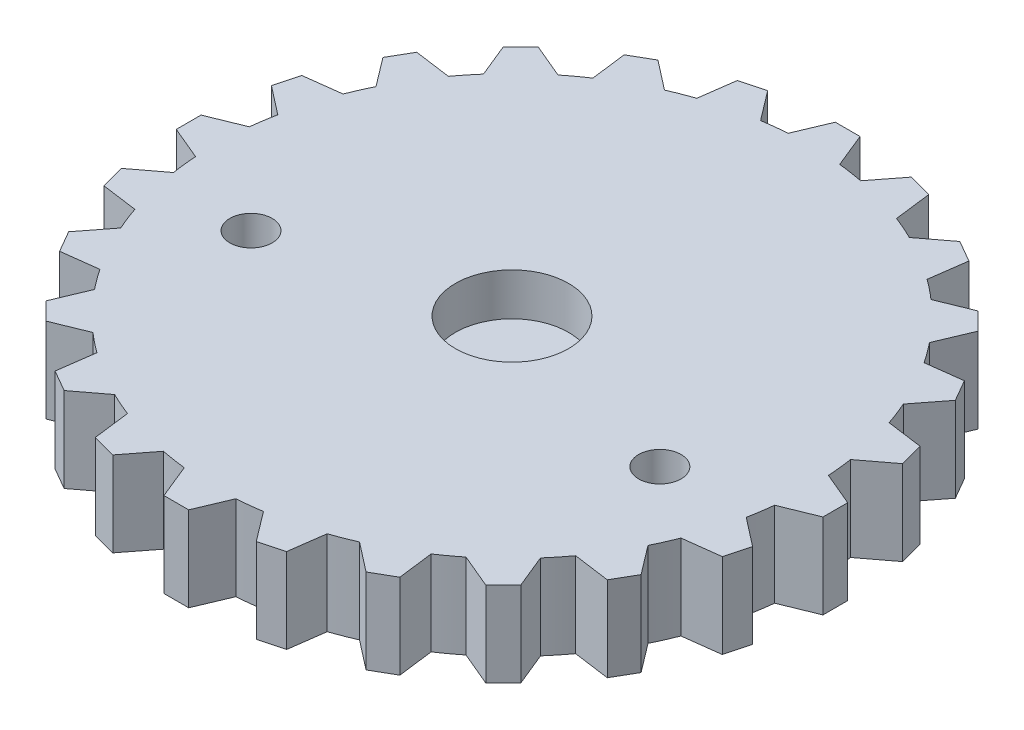
from build123d import *

# Parameters (mm, degrees)
BOSS_EXTRUDE5_DEPTH = 6
BOSS_EXTRUDE6_DEPTH = 3
SKETCH4_R           = 4
CUT_EXTRUDE1_DEPTH  = 10
SKETCH5_R           = 1.5
CUT_EXTRUDE2_DEPTH  = 7


with BuildPart() as part:
    # Sketch3 → Boss-Extrude5 (new body)
    with BuildSketch(Plane(origin=(0, 0, 0), x_dir=(1, 0, 0), z_dir=(0, 1, 0))):
        with BuildLine():
            Line((23.301465589, -1.311541929), (23.301465589, 0.438458071))
            Line((23.301465589, 0.438458071), (20.951465589, 1.426916143))
            ThreePointArc((20.951465589, 1.426916143), (20.873013262, 2.30593091), (20.757698449, 3.180873321))
            Line((20.757698449, 3.180873321), (22.846939432, 4.764010852))
            Line((22.846939432, 4.764010852), (22.394006103, 6.454381048))
            Line((22.394006103, 6.454381048), (19.868248637, 6.800933471))
            ThreePointArc((19.868248637, 6.800933471), (19.564963746, 7.629691581), (19.227126431, 8.444975382))
            Line((19.227126431, 8.444975382), (20.83543211, 10.514904166))
            Line((20.83543211, 10.514904166), (19.96043211, 12.030448623))
            Line((19.96043211, 12.030448623), (17.431043375, 11.711478423))
            ThreePointArc((17.431043375, 11.711478423), (16.923594283, 12.433501379), (16.386257521, 13.133566327))
            Line((16.386257521, 13.133566327), (17.404024521, 15.549224138))
            Line((17.404024521, 15.549224138), (16.166587654, 16.786661005))
            Line((16.166587654, 16.786661005), (13.805941313, 15.823905474))
            ThreePointArc((13.805941313, 15.823905474), (13.128909838, 16.389988605), (12.42869224, 16.927126431))
            Line((12.42869224, 16.927126431), (12.786561423, 19.523890181))
            Line((12.786561423, 19.523890181), (11.271016966, 20.398890181))
            Line((11.271016966, 20.398890181), (9.239987166, 18.857959518))
            ThreePointArc((9.239987166, 18.857959518), (8.439511883, 19.229525194), (7.624132122, 19.567130842))
            Line((7.624132122, 19.567130842), (7.297715294, 22.168035373))
            Line((7.297715294, 22.168035373), (5.607345098, 22.620968702))
            Line((5.607345098, 22.620968702), (4.044343163, 20.606874784))
            ThreePointArc((4.044343163, 20.606874784), (3.174975141, 20.758601419), (2.3, 20.873667622))
            Line((2.3, 20.873667622), (1.311541929, 23.301465589))
            Line((1.311541929, 23.301465589), (-0.438458071, 23.301465589))
            Line((-0.438458071, 23.301465589), (-1.426916143, 20.951465589))
            ThreePointArc((-1.426916143, 20.951465589), (-2.30593091, 20.873013262), (-3.180873321, 20.757698449))
            Line((-3.180873321, 20.757698449), (-4.764010852, 22.846939432))
            Line((-4.764010852, 22.846939432), (-6.454381048, 22.394006103))
            Line((-6.454381048, 22.394006103), (-6.800933471, 19.868248637))
            ThreePointArc((-6.800933471, 19.868248637), (-7.629691581, 19.564963746), (-8.444975382, 19.227126431))
            Line((-8.444975382, 19.227126431), (-10.514904166, 20.83543211))
            Line((-10.514904166, 20.83543211), (-12.030448623, 19.96043211))
            Line((-12.030448623, 19.96043211), (-11.711478423, 17.431043375))
            ThreePointArc((-11.711478423, 17.431043375), (-12.433501379, 16.923594283), (-13.133566327, 16.386257521))
            Line((-13.133566327, 16.386257521), (-15.549224138, 17.404024521))
            Line((-15.549224138, 17.404024521), (-16.786661005, 16.166587654))
            Line((-16.786661005, 16.166587654), (-15.823905474, 13.805941313))
            ThreePointArc((-15.823905474, 13.805941313), (-16.389988605, 13.128909838), (-16.927126431, 12.42869224))
            Line((-16.927126431, 12.42869224), (-19.523890181, 12.786561423))
            Line((-19.523890181, 12.786561423), (-20.398890181, 11.271016966))
            Line((-20.398890181, 11.271016966), (-18.857959518, 9.239987166))
            ThreePointArc((-18.857959518, 9.239987166), (-19.229525194, 8.439511883), (-19.567130842, 7.624132122))
            Line((-19.567130842, 7.624132122), (-22.168035373, 7.297715294))
            Line((-22.168035373, 7.297715294), (-22.620968702, 5.607345098))
            Line((-22.620968702, 5.607345098), (-20.606874784, 4.044343163))
            ThreePointArc((-20.606874784, 4.044343163), (-20.758601419, 3.174975141), (-20.873667622, 2.3))
            Line((-20.873667622, 2.3), (-23.301465589, 1.311541929))
            Line((-23.301465589, 1.311541929), (-23.301465589, -0.438458071))
            Line((-23.301465589, -0.438458071), (-20.951465589, -1.426916143))
            ThreePointArc((-20.951465589, -1.426916143), (-20.873013262, -2.30593091), (-20.757698449, -3.180873321))
            Line((-20.757698449, -3.180873321), (-22.846939432, -4.764010852))
            Line((-22.846939432, -4.764010852), (-22.394006103, -6.454381048))
            Line((-22.394006103, -6.454381048), (-19.868248637, -6.800933471))
            ThreePointArc((-19.868248637, -6.800933471), (-19.564963746, -7.629691581), (-19.227126431, -8.444975382))
            Line((-19.227126431, -8.444975382), (-20.83543211, -10.514904166))
            Line((-20.83543211, -10.514904166), (-19.96043211, -12.030448623))
            Line((-19.96043211, -12.030448623), (-17.431043375, -11.711478423))
            ThreePointArc((-17.431043375, -11.711478423), (-16.923594283, -12.433501379), (-16.386257521, -13.133566327))
            Line((-16.386257521, -13.133566327), (-17.404024521, -15.549224138))
            Line((-17.404024521, -15.549224138), (-16.166587654, -16.786661005))
            Line((-16.166587654, -16.786661005), (-13.805941313, -15.823905474))
            ThreePointArc((-13.805941313, -15.823905474), (-13.128909838, -16.389988605), (-12.42869224, -16.927126431))
            Line((-12.42869224, -16.927126431), (-12.786561423, -19.523890181))
            Line((-12.786561423, -19.523890181), (-11.271016966, -20.398890181))
            Line((-11.271016966, -20.398890181), (-9.239987166, -18.857959518))
            ThreePointArc((-9.239987166, -18.857959518), (-8.439511883, -19.229525194), (-7.624132122, -19.567130842))
            Line((-7.624132122, -19.567130842), (-7.297715294, -22.168035373))
            Line((-7.297715294, -22.168035373), (-5.607345098, -22.620968702))
            Line((-5.607345098, -22.620968702), (-4.044343163, -20.606874784))
            ThreePointArc((-4.044343163, -20.606874784), (-3.174975141, -20.758601419), (-2.3, -20.873667622))
            Line((-2.3, -20.873667622), (-1.311541929, -23.301465589))
            Line((-1.311541929, -23.301465589), (0.438458071, -23.301465589))
            Line((0.438458071, -23.301465589), (1.426916143, -20.951465589))
            ThreePointArc((1.426916143, -20.951465589), (2.30593091, -20.873013262), (3.180873321, -20.757698449))
            Line((3.180873321, -20.757698449), (4.764010852, -22.846939432))
            Line((4.764010852, -22.846939432), (6.454381048, -22.394006103))
            Line((6.454381048, -22.394006103), (6.800933471, -19.868248637))
            ThreePointArc((6.800933471, -19.868248637), (7.629691581, -19.564963746), (8.444975382, -19.227126431))
            Line((8.444975382, -19.227126431), (10.514904166, -20.83543211))
            Line((10.514904166, -20.83543211), (12.030448623, -19.96043211))
            Line((12.030448623, -19.96043211), (11.711478423, -17.431043375))
            ThreePointArc((11.711478423, -17.431043375), (12.433501379, -16.923594283), (13.133566327, -16.386257521))
            Line((13.133566327, -16.386257521), (15.549224138, -17.404024521))
            Line((15.549224138, -17.404024521), (16.786661005, -16.166587654))
            Line((16.786661005, -16.166587654), (15.823905474, -13.805941313))
            ThreePointArc((15.823905474, -13.805941313), (16.389988605, -13.128909838), (16.927126431, -12.42869224))
            Line((16.927126431, -12.42869224), (19.523890181, -12.786561423))
            Line((19.523890181, -12.786561423), (20.398890181, -11.271016966))
            Line((20.398890181, -11.271016966), (18.857959518, -9.239987166))
            ThreePointArc((18.857959518, -9.239987166), (19.229525194, -8.439511883), (19.567130842, -7.624132122))
            Line((19.567130842, -7.624132122), (22.168035373, -7.297715294))
            Line((22.168035373, -7.297715294), (22.620968702, -5.607345098))
            Line((22.620968702, -5.607345098), (20.606874784, -4.044343163))
            ThreePointArc((20.606874784, -4.044343163), (20.758601419, -3.174975141), (20.873667622, -2.3))
            Line((20.873667622, -2.3), (23.301465589, -1.311541929))
        make_face()
    extrude(amount=BOSS_EXTRUDE5_DEPTH)

    # Sketch4 → Cut-Extrude1 (cut)
    with BuildSketch(Plane(origin=(0, 6, 0), x_dir=(1, 0, 0), z_dir=(0, 1, 0))):
        Circle(SKETCH4_R)
    extrude(amount=-CUT_EXTRUDE1_DEPTH, mode=Mode.SUBTRACT)

    # Sketch5 → Cut-Extrude2 (cut, through all)
    with BuildSketch(Plane(origin=(0, 6, 0), x_dir=(1, 0, 0), z_dir=(0, 1, 0))):
        with Locations((-14.456832295, -4)):
            Circle(SKETCH5_R)
        with Locations((14.456832295, -4)):
            Circle(SKETCH5_R)
    extrude(amount=-CUT_EXTRUDE2_DEPTH, mode=Mode.SUBTRACT)


with BuildPart() as body_2:
    # Sketch1 → Boss-Extrude6 (new body)
    with BuildSketch(Plane(origin=(0, 0, 0), x_dir=(1, 0, 0), z_dir=(0, 1, 0))):
        with BuildLine():
            Line((-0.5, 14.746169466), (0.5, 14.746169466))
            Line((0.5, 14.746169466), (2, 12.544128437))
            ThreePointArc((2, 12.544128437), (2.588190451, 12.405427729), (3.166928678, 12.23145084))
            Line((3.166928678, 12.23145084), (5.566987298, 13.388474311))
            Line((5.566987298, 13.388474311), (6.433012702, 12.888474311))
            Line((6.433012702, 12.888474311), (6.631030293, 10.23145084))
            ThreePointArc((6.631030293, 10.23145084), (7.071067812, 9.817237278), (7.485281374, 9.377199759))
            Line((7.485281374, 9.377199759), (10.142304845, 9.179182168))
            Line((10.142304845, 9.179182168), (10.642304845, 8.313156764))
            Line((10.642304845, 8.313156764), (9.485281374, 5.913098144))
            ThreePointArc((9.485281374, 5.913098144), (9.659258263, 5.334359917), (9.797958971, 4.746169466))
            Line((9.797958971, 4.746169466), (12, 3.246169466))
            Line((12, 3.246169466), (12, 2.246169466))
            Line((12, 2.246169466), (9.797958971, 0.746169466))
            ThreePointArc((9.797958971, 0.746169466), (9.659258263, 0.157979015), (9.485281374, -0.420759212))
            Line((9.485281374, -0.420759212), (10.642304845, -2.820817832))
            Line((10.642304845, -2.820817832), (10.142304845, -3.686843236))
            Line((10.142304845, -3.686843236), (7.485281374, -3.884860827))
            ThreePointArc((7.485281374, -3.884860827), (7.071067812, -4.324898346), (6.631030293, -4.739111908))
            Line((6.631030293, -4.739111908), (6.433012702, -7.39613538))
            Line((6.433012702, -7.39613538), (5.566987298, -7.89613538))
            Line((5.566987298, -7.89613538), (3.166928678, -6.739111908))
            ThreePointArc((3.166928678, -6.739111908), (2.588190451, -6.913088797), (2, -7.051789505))
            Line((2, -7.051789505), (0.5, -9.253830534))
            Line((0.5, -9.253830534), (-0.5, -9.253830534))
            Line((-0.5, -9.253830534), (-2, -7.051789505))
            ThreePointArc((-2, -7.051789505), (-2.588190451, -6.913088797), (-3.166928678, -6.739111908))
            Line((-3.166928678, -6.739111908), (-5.566987298, -7.89613538))
            Line((-5.566987298, -7.89613538), (-6.433012702, -7.39613538))
            Line((-6.433012702, -7.39613538), (-6.631030293, -4.739111908))
            ThreePointArc((-6.631030293, -4.739111908), (-7.071067812, -4.324898346), (-7.485281374, -3.884860827))
            Line((-7.485281374, -3.884860827), (-10.142304845, -3.686843236))
            Line((-10.142304845, -3.686843236), (-10.642304845, -2.820817832))
            Line((-10.642304845, -2.820817832), (-9.485281374, -0.420759212))
            ThreePointArc((-9.485281374, -0.420759212), (-9.659258263, 0.157979015), (-9.797958971, 0.746169466))
            Line((-9.797958971, 0.746169466), (-12, 2.246169466))
            Line((-12, 2.246169466), (-12, 3.246169466))
            Line((-12, 3.246169466), (-9.797958971, 4.746169466))
            ThreePointArc((-9.797958971, 4.746169466), (-9.659258263, 5.334359917), (-9.485281374, 5.913098144))
            Line((-9.485281374, 5.913098144), (-10.642304845, 8.313156764))
            Line((-10.642304845, 8.313156764), (-10.142304845, 9.179182168))
            Line((-10.142304845, 9.179182168), (-7.485281374, 9.377199759))
            ThreePointArc((-7.485281374, 9.377199759), (-7.071067812, 9.817237278), (-6.631030293, 10.23145084))
            Line((-6.631030293, 10.23145084), (-6.433012702, 12.888474311))
            Line((-6.433012702, 12.888474311), (-5.566987298, 13.388474311))
            Line((-5.566987298, 13.388474311), (-3.166928678, 12.23145084))
            ThreePointArc((-3.166928678, 12.23145084), (-2.588190451, 12.405427729), (-2, 12.544128437))
            Line((-2, 12.544128437), (-0.5, 14.746169466))
        make_face()
    extrude(amount=BOSS_EXTRUDE6_DEPTH)


solid = Compound([part.part, body_2.part])
